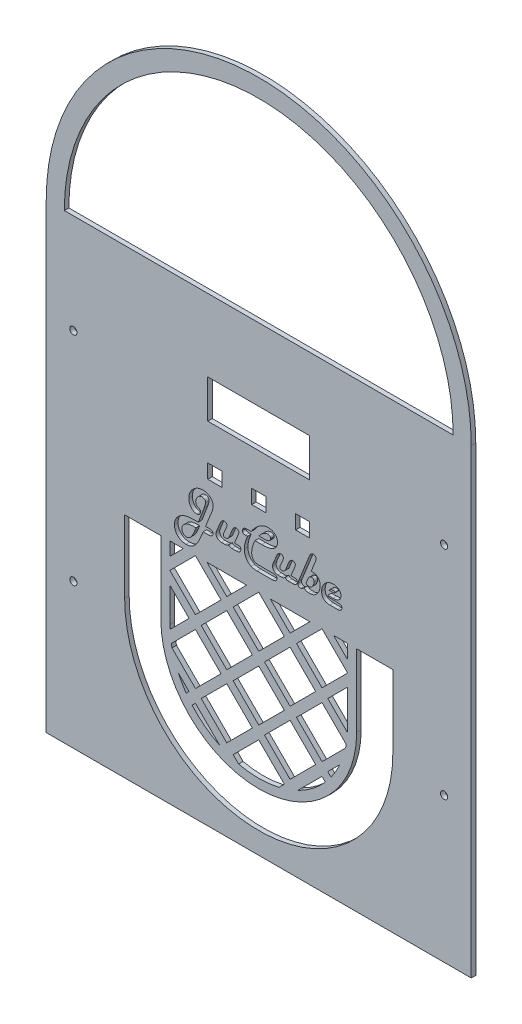
from build123d import *

# Parameters (mm, degrees)
SKETCH1_R           = 2.54
SKETCH1_W           = 71.628
SKETCH1_H           = 26.924
SKETCH1_W_2         = 9.906
SKETCH1_H_2         = 9.906
BOSS_EXTRUDE1_DEPTH = 3.175
CUT_EXTRUDE3_DEPTH  = 2.54
CUT_EXTRUDE4_DEPTH  = 4.175
CUT_EXTRUDE5_DEPTH  = 25.4


with BuildPart() as part:
    # Sketch1 → Boss-Extrude1 (new body)
    with BuildSketch(Plane.XY):
        with BuildLine():
            Line((0, 0), (0, -323.85))
            Line((0, -323.85), (298.45, -323.85))
            Line((298.45, -323.85), (298.45, 0))
            ThreePointArc((298.45, 0), (149.225, 149.225), (0, 0))
        make_face()
        with Locations((19.05, -69.85)):
            Circle(SKETCH1_R, mode=Mode.SUBTRACT)
        with Locations((19.05, -222.25)):
            Circle(SKETCH1_R, mode=Mode.SUBTRACT)
        with Locations((279.4, -69.85)):
            Circle(SKETCH1_R, mode=Mode.SUBTRACT)
        with Locations((279.4, -222.25)):
            Circle(SKETCH1_R, mode=Mode.SUBTRACT)
        with BuildLine():
            Line((12.7, 0), (285.75, 0))
            ThreePointArc((285.75, 0), (149.225, 136.525), (12.7, 0))
        make_face(mode=Mode.SUBTRACT)
        with Locations((149.225, -64.262)):
            Rectangle(SKETCH1_W, SKETCH1_H, mode=Mode.SUBTRACT)
        with Locations((118.364, -108.077)):
            Rectangle(SKETCH1_W_2, SKETCH1_H_2, mode=Mode.SUBTRACT)
        with Locations((149.225, -108.077)):
            Rectangle(SKETCH1_W_2, SKETCH1_H_2, mode=Mode.SUBTRACT)
        with Locations((180.086, -108.077)):
            Rectangle(SKETCH1_W_2, SKETCH1_H_2, mode=Mode.SUBTRACT)
    extrude(amount=BOSS_EXTRUDE1_DEPTH)

    # Sketch3 → Cut-Extrude3 (cut)
    with BuildSketch(Plane.XY.offset(3.175)):
        with BuildLine():
            Line((111.90535525, -142.473594956), (114.634550456, -142.473594956))
            add(Edge.make_bspline(
                [(114.634550456, -142.473594956), (114.832478374, -142.477826627), (115.203074422, -142.485749919), (115.717583256, -142.568194866), (116.158749376, -142.6923425), (116.518291611, -142.885660169), (116.80878151, -143.126935007), (117.009530641, -143.433806599), (117.134639848, -143.792636287), (117.14584922, -144.050935819), (117.151716551, -144.186137764)],
                knots=[0, 0, 0, 0, 0.000593217, 0.001110728, 0.001559605, 0.00196096, 0.002327158, 0.002679995, 0.003047924, 0.003452032, 0.003452032, 0.003452032, 0.003452032], degree=3))
            add(Edge.make_bspline(
                [(117.151716551, -144.186137764), (117.142623611, -144.3688148), (117.125003616, -144.722800232), (116.948227754, -145.222895393), (116.657660102, -145.657034246), (116.25720441, -146.020076712), (115.757901802, -146.301177666), (115.173849529, -146.50900938), (114.501265319, -146.624231385), (114.026079151, -146.640408721), (113.775560729, -146.648937422)],
                knots=[0, 0, 0, 0, 0.000546376, 0.001058749, 0.001568404, 0.002099416, 0.002664514, 0.00327671, 0.003950678, 0.004702195, 0.004702195, 0.004702195, 0.004702195], degree=3))
            Line((113.775560729, -146.648937422), (110.17650251, -146.648937422))
            Line((110.17650251, -146.648937422), (108.806468264, -150.025093244))
            add(Edge.make_bspline(
                [(108.806468264, -150.025093244), (108.623530561, -150.476113823), (108.269592219, -151.348724956), (107.694707707, -152.590462068), (107.119679303, -153.730823041), (106.547677927, -154.776348793), (105.953732636, -155.709392953), (105.360798138, -156.545884434), (104.767321838, -157.285246223), (104.150439583, -157.91648381), (103.517313202, -158.467290318), (102.846174483, -158.93300141), (102.142598922, -159.33567492), (101.394940149, -159.655586518), (100.613549476, -159.912784851), (99.792047744, -160.092159729), (98.934343662, -160.1950215), (98.35026586, -160.210776295), (98.052786757, -160.218800435)],
                knots=[0, 0, 0, 0, 0.001459949, 0.002824633, 0.004103528, 0.00529112, 0.006398182, 0.00741949, 0.008366231, 0.00923896, 0.010063934, 0.010879884, 0.011685718, 0.012491681, 0.013315203, 0.014150201, 0.015009982, 0.015902403, 0.015902403, 0.015902403, 0.015902403], degree=3))
            add(Edge.make_bspline(
                [(98.052786757, -160.218800435), (97.771470821, -160.213876332), (97.219304863, -160.204211319), (96.41037259, -160.08829336), (95.635534419, -159.918613957), (94.896408891, -159.671080357), (94.192319998, -159.356093583), (93.524939167, -158.96594122), (92.89207252, -158.508231786), (92.303018609, -157.982633056), (91.768244669, -157.405023998), (91.298356068, -156.788021845), (90.89565242, -156.138561716), (90.577664695, -155.447799073), (90.317844623, -154.728956071), (90.138613152, -153.972188794), (90.035923276, -153.18119214), (90.020055656, -152.64222887), (90.011990524, -152.368286737)],
                knots=[0, 0, 0, 0, 0.000843311, 0.001655248, 0.002446611, 0.003220259, 0.003989213, 0.004756627, 0.005535264, 0.00632853, 0.00712105, 0.007893072, 0.008652064, 0.009408461, 0.010170232, 0.010941641, 0.011736694, 0.012558508, 0.012558508, 0.012558508, 0.012558508], degree=3))
            add(Edge.make_bspline(
                [(90.011990524, -152.368286737), (90.015921844, -152.159684581), (90.023701515, -151.746882781), (90.09337593, -151.135173483), (90.194272266, -150.535078671), (90.34221087, -149.946398741), (90.532718901, -149.368459542), (90.767293755, -148.804324806), (91.039937957, -148.251261731), (91.356201416, -147.714830383), (91.707002647, -147.192965348), (92.101400857, -146.696580588), (92.531821115, -146.224391993), (92.993375242, -145.772688806), (93.489652047, -145.34586947), (94.025206295, -144.951332057), (94.59117916, -144.572242012), (94.990459925, -144.344977458), (95.193112099, -144.229630915)],
                knots=[0, 0, 0, 0, 0.000625592, 0.001237981, 0.001844868, 0.002450096, 0.003056982, 0.003668816, 0.004281519, 0.004905313, 0.005535612, 0.006166473, 0.006805366, 0.007451252, 0.008102856, 0.008767217, 0.009445753, 0.010145075, 0.010145075, 0.010145075, 0.010145075], degree=3))
            add(Edge.make_bspline(
                [(95.193112099, -144.229630915), (95.466306799, -144.090514363), (96.025496846, -143.805762898), (96.931112347, -143.464014052), (97.904599722, -143.161091862), (98.956974743, -142.929090313), (100.079229838, -142.734422113), (101.278180694, -142.611062871), (102.551269272, -142.525489747), (103.425846106, -142.516349904), (103.875432305, -142.511651463)],
                knots=[0, 0, 0, 0, 0.000919098, 0.001881261, 0.002899323, 0.003975518, 0.005111516, 0.006314674, 0.007589459, 0.008938021, 0.008938021, 0.008938021, 0.008938021], degree=3))
            Line((103.875432305, -142.511651463), (106.800346688, -142.473594956))
            Line((106.800346688, -142.473594956), (110.883266209, -131.736223381))
            add(Edge.make_bspline(
                [(110.883266209, -131.736223381), (110.965722331, -131.511828047), (111.122901044, -131.084083342), (111.333736407, -130.466845729), (111.522579557, -129.909156956), (111.668610734, -129.402438211), (111.783837147, -128.952902971), (111.866718302, -128.559581734), (111.920521095, -128.221999442), (111.928786328, -128.014085457), (111.932538469, -127.919699408)],
                knots=[0, 0, 0, 0, 0.000717163, 0.001367064, 0.001956758, 0.002483243, 0.002948704, 0.003348546, 0.003689151, 0.003972327, 0.003972327, 0.003972327, 0.003972327], degree=3))
            add(Edge.make_bspline(
                [(111.932538469, -127.919699408), (111.925417179, -127.778778004), (111.911254061, -127.498507672), (111.757328477, -127.099093563), (111.52628619, -126.726622452), (111.201710473, -126.401120025), (110.82452526, -126.120549929), (110.39683875, -125.915316763), (109.933335048, -125.79172576), (109.611853781, -125.778808912), (109.447992236, -125.772225093)],
                knots=[0, 0, 0, 0, 0.000420875, 0.000837053, 0.001266961, 0.00172834, 0.002206795, 0.002671239, 0.00314332, 0.003634095, 0.003634095, 0.003634095, 0.003634095], degree=3))
            add(Edge.make_bspline(
                [(109.447992236, -125.772225093), (109.308092934, -125.777722214), (109.029865685, -125.788654713), (108.617548066, -125.868750723), (108.214232483, -125.993563773), (107.819157296, -126.168902888), (107.436010971, -126.399357172), (107.06850339, -126.68696572), (106.700087147, -127.012600697), (106.353183845, -127.389841903), (106.033841309, -127.796596885), (105.744301745, -128.215667633), (105.514978744, -128.65359035), (105.313585179, -129.096036159), (105.162384605, -129.553803305), (105.054097307, -130.021487099), (104.985568031, -130.500084182), (104.977645872, -130.822636849), (104.97363436, -130.985966531)],
                knots=[0, 0, 0, 0, 0.000419503, 0.000834295, 0.001255591, 0.001683948, 0.00212776, 0.002593157, 0.003082122, 0.003601457, 0.004127886, 0.004633026, 0.005126804, 0.005608706, 0.006090087, 0.006570116, 0.007047582, 0.007537363, 0.007537363, 0.007537363, 0.007537363], degree=3))
            add(Edge.make_bspline(
                [(104.97363436, -130.985966531), (104.979856751, -131.154911956), (104.991801412, -131.479223894), (105.082852255, -131.938769706), (105.237585257, -132.344623468), (105.452096985, -132.708114169), (105.763718356, -133.017675774), (106.150125877, -133.306995127), (106.625419515, -133.577978575), (106.981558843, -133.728123486), (107.170038469, -133.807584682)],
                knots=[0, 0, 0, 0, 0.000506659, 0.000972596, 0.001397663, 0.001805121, 0.002228063, 0.002705405, 0.003250942, 0.003864223, 0.003864223, 0.003864223, 0.003864223], degree=3))
            add(Edge.make_bspline(
                [(107.170038469, -133.807584682), (107.270955932, -133.852270837), (107.46577068, -133.93853462), (107.728699287, -134.103433549), (107.953338883, -134.286852987), (108.134796569, -134.491638266), (108.283203492, -134.712139497), (108.377482635, -134.959866908), (108.440301409, -135.223447985), (108.448770973, -135.405580249), (108.453086414, -135.498380915)],
                knots=[0, 0, 0, 0, 0.000330743, 0.000638478, 0.000928053, 0.001197592, 0.00145696, 0.001720455, 0.001988179, 0.002266299, 0.002266299, 0.002266299, 0.002266299], degree=3))
            add(Edge.make_bspline(
                [(108.453086414, -135.498380915), (108.443922003, -135.6661088), (108.425915779, -135.995660348), (108.275870608, -136.469086226), (108.014028156, -136.889397892), (107.67471744, -137.265030041), (107.254542296, -137.564701486), (106.784637277, -137.796076577), (106.259958499, -137.926462446), (105.894926154, -137.942220043), (105.707581277, -137.950307285)],
                knots=[0, 0, 0, 0, 0.000502559, 0.000987427, 0.001470402, 0.001978372, 0.002495996, 0.003009061, 0.003541769, 0.00410343, 0.00410343, 0.00410343, 0.00410343], degree=3))
            add(Edge.make_bspline(
                [(105.707581277, -137.950307285), (105.516995055, -137.943264009), (105.141099258, -137.929372461), (104.587517044, -137.842268554), (104.055478107, -137.690004827), (103.548348223, -137.466761032), (103.056452612, -137.197712302), (102.58987538, -136.859144735), (102.144385528, -136.463111121), (101.729971353, -136.005973177), (101.347955563, -135.512901136), (101.010461447, -134.987242145), (100.737650286, -134.429432461), (100.500112594, -133.853899826), (100.318846966, -133.249484268), (100.197483123, -132.619026977), (100.118285912, -131.962931929), (100.10775746, -131.517179387), (100.102401483, -131.290418586)],
                knots=[0, 0, 0, 0, 0.000571779, 0.001127727, 0.001676613, 0.002227004, 0.002786741, 0.00335554, 0.003952408, 0.004571923, 0.005203721, 0.00582209, 0.006442082, 0.007063978, 0.00768834, 0.008331268, 0.00898809, 0.009668214, 0.009668214, 0.009668214, 0.009668214], degree=3))
            add(Edge.make_bspline(
                [(100.102401483, -131.290418586), (100.111891643, -130.958249715), (100.130648113, -130.30174707), (100.277369528, -129.33487824), (100.508242542, -128.39866099), (100.846240866, -127.500063312), (101.2612477, -126.627009535), (101.793811409, -125.801013426), (102.402569477, -124.99607617), (103.103536387, -124.238608487), (103.869607513, -123.547238087), (104.666327023, -122.922353373), (105.511513176, -122.415310034), (106.378349286, -121.981352104), (107.287532091, -121.659456361), (108.222994042, -121.414761101), (109.195770925, -121.279330634), (109.853540812, -121.25916964), (110.187375798, -121.248937422)],
                knots=[0, 0, 0, 0, 0.000996108, 0.001968721, 0.002927329, 0.003883715, 0.004844172, 0.005821559, 0.006826279, 0.007868939, 0.008911939, 0.009919964, 0.010900852, 0.011863691, 0.012823317, 0.013788531, 0.014760368, 0.015761907, 0.015761907, 0.015761907, 0.015761907], degree=3))
            add(Edge.make_bspline(
                [(110.187375798, -121.248937422), (110.430478744, -121.253565467), (110.909242899, -121.262679887), (111.609592432, -121.352044036), (112.280175801, -121.495125478), (112.921525491, -121.686451853), (113.52932949, -121.947063304), (114.107176811, -122.256464192), (114.655084887, -122.622359305), (115.162379431, -123.046080963), (115.627010587, -123.509570507), (116.037805274, -124.004678382), (116.383031928, -124.529527165), (116.662848907, -125.084456209), (116.87991109, -125.668293487), (117.038994409, -126.279934149), (117.132494757, -126.921914625), (117.145222848, -127.359418698), (117.151716551, -127.58262749)],
                knots=[0, 0, 0, 0, 0.000729017, 0.001435718, 0.002113884, 0.002784599, 0.003439934, 0.004094254, 0.004748665, 0.005412737, 0.006073954, 0.006715063, 0.007339331, 0.007954465, 0.008575505, 0.00920449, 0.009847257, 0.010516759, 0.010516759, 0.010516759, 0.010516759], degree=3))
            add(Edge.make_bspline(
                [(117.151716551, -127.58262749), (117.138983203, -127.886021046), (117.112177017, -128.52472373), (116.917724713, -129.522284277), (116.611257329, -130.604307412), (116.334626311, -131.343044659), (116.189430593, -131.730786737)],
                knots=[0, 0, 0, 0, 0.000909887, 0.00191549, 0.003039403, 0.004280983, 0.004280983, 0.004280983, 0.004280983], degree=3))
            Line((116.189430593, -131.730786737), (111.90535525, -142.473594956))
        make_face()
        with BuildLine():
            add(Edge.make_bspline(
                [(105.169353538, -146.648937422), (104.859404522, -146.650164761), (104.259187169, -146.652541509), (103.387486439, -146.695206769), (102.571113383, -146.744975331), (101.809009222, -146.825383809), (101.10433082, -146.936121594), (100.453437913, -147.057522213), (99.859442252, -147.208256485), (99.487383632, -147.333562323), (99.308651483, -147.393757627)],
                knots=[0, 0, 0, 0, 0.00092973, 0.001800425, 0.002617732, 0.003383218, 0.004098297, 0.004757231, 0.005369064, 0.005934711, 0.005934711, 0.005934711, 0.005934711], degree=3))
            add(Edge.make_bspline(
                [(99.308651483, -147.393757627), (99.00584563, -147.512540454), (98.41762445, -147.743284258), (97.619830629, -148.214558443), (96.913999856, -148.748218998), (96.31581194, -149.355592132), (95.833892884, -150.017758313), (95.481964323, -150.723479112), (95.274489467, -151.468666713), (95.245630277, -151.97742569), (95.231168606, -152.232370641)],
                knots=[0, 0, 0, 0, 0.000974434, 0.001892905, 0.002769335, 0.003622802, 0.004440615, 0.005216228, 0.005977241, 0.006741646, 0.006741646, 0.006741646, 0.006741646], degree=3))
            add(Edge.make_bspline(
                [(95.231168606, -152.232370641), (95.24233771, -152.46550329), (95.264136051, -152.920499961), (95.444611458, -153.574036631), (95.737232717, -154.171926989), (96.138123977, -154.70121799), (96.623274053, -155.142392153), (97.174736484, -155.464398769), (97.781060047, -155.65825016), (98.201791499, -155.682901099), (98.417041894, -155.695512764)],
                knots=[0, 0, 0, 0, 0.000698455, 0.00136315, 0.002017199, 0.002684823, 0.003343106, 0.003971597, 0.004587163, 0.005231996, 0.005231996, 0.005231996, 0.005231996], degree=3))
            add(Edge.make_bspline(
                [(98.417041894, -155.695512764), (98.556890023, -155.691802591), (98.834798823, -155.684429665), (99.245536895, -155.610603889), (99.645440177, -155.491003412), (100.0322397, -155.319500239), (100.41065156, -155.106806543), (100.776235736, -154.843346775), (101.128606313, -154.531374449), (101.475057634, -154.174240023), (101.813076679, -153.76206201), (102.148262329, -153.293786693), (102.484546052, -152.770591915), (102.823353275, -152.193704922), (103.153216136, -151.554949052), (103.482796372, -150.859559527), (103.817339865, -150.109058011), (104.024258376, -149.583759613), (104.130954565, -149.312892901)],
                knots=[0, 0, 0, 0, 0.000419186, 0.000833014, 0.00124752, 0.001668711, 0.002099615, 0.002547701, 0.003017711, 0.00350984, 0.004038873, 0.00461526, 0.005236562, 0.005904185, 0.006621534, 0.007392407, 0.008212692, 0.009085963, 0.009085963, 0.009085963, 0.009085963], degree=3))
            Line((104.130954565, -149.312892901), (105.169353538, -146.648937422))
        make_face(mode=Mode.SUBTRACT)
        with BuildLine():
            Line((132.162290182, -142.473594956), (134.288017921, -142.473594956))
            add(Edge.make_bspline(
                [(134.288017921, -142.473594956), (134.485900768, -142.475874366), (134.852613126, -142.480098521), (135.354381047, -142.55669005), (135.769522285, -142.669970764), (136.099074898, -142.845072202), (136.345820374, -143.085969294), (136.519487229, -143.387950707), (136.62218335, -143.753769835), (136.631641683, -144.018716211), (136.636648058, -144.158954545)],
                knots=[0, 0, 0, 0, 0.000592993, 0.001098922, 0.001518637, 0.001878771, 0.002205558, 0.00253937, 0.002912761, 0.003332651, 0.003332651, 0.003332651, 0.003332651], degree=3))
            add(Edge.make_bspline(
                [(136.636648058, -144.158954545), (136.629257965, -144.345148997), (136.615043562, -144.703282912), (136.449481666, -145.205120361), (136.187578335, -145.643565606), (135.821747063, -146.011927513), (135.361692351, -146.300905167), (134.817423584, -146.509142975), (134.191274087, -146.623811238), (133.748438545, -146.640289), (133.516014497, -146.648937422)],
                knots=[0, 0, 0, 0, 0.000556692, 0.001070764, 0.001565857, 0.002077162, 0.002612554, 0.003183997, 0.003815209, 0.004512458, 0.004512458, 0.004512458, 0.004512458], degree=3))
            Line((133.516014497, -146.648937422), (130.23228162, -146.648937422))
            add(Edge.make_bspline(
                [(130.23228162, -146.648937422), (130.108879959, -146.6440815), (129.871707587, -146.63474864), (129.530721253, -146.582790189), (129.221564993, -146.485337048), (128.948353029, -146.341549623), (128.704324562, -146.164510497), (128.487865828, -145.952010349), (128.313846091, -145.690139012), (128.223669948, -145.497642748), (128.17723025, -145.39850934)],
                knots=[0, 0, 0, 0, 0.000370331, 0.000711759, 0.001031552, 0.00133794, 0.001633725, 0.001933579, 0.002242704, 0.002570935, 0.002570935, 0.002570935, 0.002570935], degree=3))
            add(Edge.make_bspline(
                [(128.17723025, -145.39850934), (128.091891573, -145.497855941), (127.925498795, -145.691561276), (127.652750936, -145.951880909), (127.356397918, -146.164426959), (127.044540425, -146.336909183), (126.721646257, -146.484204894), (126.378717265, -146.580063002), (126.018814033, -146.634563073), (125.77442256, -146.644067261), (125.649190866, -146.648937422)],
                knots=[0, 0, 0, 0, 0.000392795, 0.000765869, 0.001128009, 0.001483392, 0.001833919, 0.002190133, 0.002547672, 0.002923431, 0.002923431, 0.002923431, 0.002923431], degree=3))
            Line((125.649190866, -146.648937422), (122.968925456, -146.648937422))
            add(Edge.make_bspline(
                [(122.968925456, -146.648937422), (122.710342074, -146.638892963), (122.209551797, -146.619440178), (121.495513249, -146.42765411), (120.849744348, -146.118845457), (120.285667377, -145.689535381), (119.823287493, -145.16396696), (119.481743816, -144.561906183), (119.27297581, -143.89157646), (119.250755719, -143.421071742), (119.239387784, -143.180358655)],
                knots=[0, 0, 0, 0, 0.000774316, 0.001499594, 0.002199888, 0.002909927, 0.003611106, 0.004285447, 0.004973349, 0.005693946, 0.005693946, 0.005693946, 0.005693946], degree=3))
            add(Edge.make_bspline(
                [(119.239387784, -143.180358655), (119.244295913, -143.031293371), (119.254617414, -142.717818032), (119.357434279, -142.234807009), (119.502325849, -141.713810893), (119.640127581, -141.363394111), (119.712375798, -141.179673723)],
                knots=[0, 0, 0, 0, 0.000446633, 0.000939242, 0.001476178, 0.002067948, 0.002067948, 0.002067948, 0.002067948], degree=3))
            Line((119.712375798, -141.179673723), (122.186048743, -135.215675435))
            add(Edge.make_bspline(
                [(122.186048743, -135.215675435), (122.273135849, -135.020031022), (122.439519661, -134.646243621), (122.732782882, -134.138663174), (123.050269894, -133.704475528), (123.396859964, -133.351997067), (123.765313241, -133.068762421), (124.164875155, -132.879985401), (124.584592738, -132.749940394), (124.876193537, -132.737456195), (125.023976825, -132.731129203)],
                knots=[0, 0, 0, 0, 0.0006421, 0.00122676, 0.001755206, 0.002251134, 0.002705639, 0.003140876, 0.003571024, 0.004013034, 0.004013034, 0.004013034, 0.004013034], degree=3))
            add(Edge.make_bspline(
                [(125.023976825, -132.731129203), (125.14976699, -132.734845329), (125.394205904, -132.742066607), (125.742476559, -132.842089431), (126.066444774, -132.987776515), (126.348062463, -133.200425949), (126.589559856, -133.447306592), (126.768554206, -133.729396898), (126.877817585, -134.042686121), (126.888662592, -134.261584411), (126.894182305, -134.372995641)],
                knots=[0, 0, 0, 0, 0.000376112, 0.000730871, 0.001078689, 0.001436435, 0.001782506, 0.002109836, 0.002431334, 0.00276457, 0.00276457, 0.00276457, 0.00276457], degree=3))
            add(Edge.make_bspline(
                [(126.894182305, -134.372995641), (126.891089128, -134.462038924), (126.884597601, -134.648910505), (126.825516857, -134.93856838), (126.733025714, -135.247292452), (126.649444088, -135.45549904), (126.606040182, -135.563620641)],
                knots=[0, 0, 0, 0, 0.000266894, 0.000560121, 0.000883498, 0.001232842, 0.001232842, 0.001232842, 0.001232842], degree=3))
            Line((126.606040182, -135.563620641), (126.410321003, -136.025735367))
            Line((126.410321003, -136.025735367), (124.529242236, -140.462036737))
            Line((124.529242236, -140.462036737), (124.491185729, -140.989391189))
            add(Edge.make_bspline(
                [(124.491185729, -140.989391189), (124.483300228, -141.123465853), (124.469771223, -141.353495233), (124.461864208, -141.583782617), (124.458565866, -141.679844956)],
                knots=[0, 0, 0, 0, 0.000402899, 0.000691246, 0.000691246, 0.000691246, 0.000691246], degree=3))
            add(Edge.make_bspline(
                [(124.458565866, -141.679844956), (124.457284795, -141.741771327), (124.454834372, -141.860223595), (124.500210212, -142.025922886), (124.576808765, -142.169748704), (124.698087302, -142.279856459), (124.848319618, -142.36731541), (125.030414977, -142.432445492), (125.247173975, -142.469872072), (125.402570334, -142.472293504), (125.486091551, -142.473594956)],
                knots=[0, 0, 0, 0, 0.000184926, 0.000353725, 0.000509501, 0.000667164, 0.000837791, 0.001028694, 0.001244112, 0.001494434, 0.001494434, 0.001494434, 0.001494434], degree=3))
            add(Edge.make_bspline(
                [(125.486091551, -142.473594956), (125.662173594, -142.468627258), (126.001876747, -142.459043414), (126.489268216, -142.378933499), (126.929020173, -142.237335344), (127.321854667, -142.039310087), (127.669063594, -141.7859375), (127.971196492, -141.478312434), (128.226909847, -141.11248342), (128.351907801, -140.83768644), (128.416442579, -140.695812422)],
                knots=[0, 0, 0, 0, 0.000528055, 0.00101874, 0.001476065, 0.00190885, 0.002332943, 0.002759677, 0.003197048, 0.003663872, 0.003663872, 0.003663872, 0.003663872], degree=3))
            Line((128.416442579, -140.695812422), (130.634593264, -135.221112079))
            add(Edge.make_bspline(
                [(130.634593264, -135.221112079), (130.718261161, -135.025679297), (130.877946885, -134.652682887), (131.159695344, -134.140338403), (131.476192223, -133.709075096), (131.812665216, -133.350673449), (132.176847352, -133.067606671), (132.57543298, -132.880123875), (132.995062824, -132.749904834), (133.28667552, -132.737444235), (133.434464839, -132.731129203)],
                knots=[0, 0, 0, 0, 0.000637573, 0.001216849, 0.001749668, 0.002238029, 0.002688188, 0.003123426, 0.003553574, 0.003995583, 0.003995583, 0.003995583, 0.003995583], degree=3))
            add(Edge.make_bspline(
                [(133.434464839, -132.731129203), (133.554699134, -132.737460842), (133.789820031, -132.749842507), (134.1302058, -132.84614852), (134.442532539, -133.00475), (134.718211977, -133.223867317), (134.950094014, -133.48006178), (135.125706621, -133.767968657), (135.227064448, -134.08731416), (135.238852015, -134.308866686), (135.244867236, -134.421925435)],
                knots=[0, 0, 0, 0, 0.000360298, 0.000704571, 0.001052262, 0.001404638, 0.001754996, 0.002084126, 0.002409099, 0.002747746, 0.002747746, 0.002747746, 0.002747746], degree=3))
            add(Edge.make_bspline(
                [(135.244867236, -134.421925435), (135.238630948, -134.527421695), (135.224493517, -134.76657773), (135.127820239, -135.157333764), (134.978569486, -135.623057617), (134.84833765, -135.953993006), (134.777315866, -136.134468244)],
                knots=[0, 0, 0, 0, 0.000316495, 0.000717482, 0.00120235, 0.001783944, 0.001783944, 0.001783944, 0.001783944], degree=3))
            Line((134.777315866, -136.134468244), (132.162290182, -142.473594956))
        make_face()
        with BuildLine():
            add(Edge.make_bspline(
                [(146.640072716, -133.774964819), (146.453590686, -134.148450677), (146.087972213, -134.880710669), (145.608918113, -135.985096191), (145.204973615, -137.070558714), (144.871831909, -138.133417111), (144.614820206, -139.177636764), (144.42769274, -140.201168867), (144.315984093, -141.206180751), (144.299534116, -141.869867137), (144.291442579, -142.19632612)],
                knots=[0, 0, 0, 0, 0.0012522, 0.002455075, 0.003609347, 0.004725343, 0.005794719, 0.006833388, 0.007845028, 0.008824363, 0.008824363, 0.008824363, 0.008824363], degree=3))
            add(Edge.make_bspline(
                [(144.291442579, -142.19632612), (144.293342874, -142.417584376), (144.297026563, -142.846489626), (144.359975448, -143.463715225), (144.450193466, -144.034701415), (144.57722769, -144.556556662), (144.749834446, -145.027829239), (144.944596152, -145.457106377), (145.196255556, -145.828060387), (145.472091065, -146.161992844), (145.803876721, -146.443585691), (146.177625491, -146.688044334), (146.605213277, -146.889608886), (147.076963707, -147.05648381), (147.599293162, -147.187917947), (148.170917921, -147.275467406), (148.791546028, -147.339599109), (149.222294347, -147.343043807), (149.445380935, -147.344827833)],
                knots=[0, 0, 0, 0, 0.000663471, 0.001286127, 0.001859042, 0.002397023, 0.002894022, 0.003363372, 0.003806683, 0.0042348, 0.004658788, 0.005106644, 0.005571087, 0.006073204, 0.006605912, 0.007184193, 0.007806849, 0.008475755, 0.008475755, 0.008475755, 0.008475755], degree=3))
            Line((149.445380935, -147.344827833), (159.649961414, -147.344827833))
            add(Edge.make_bspline(
                [(159.649961414, -147.344827833), (159.836956821, -147.34959977), (160.187325265, -147.358540825), (160.676668967, -147.434893655), (161.095123109, -147.552845118), (161.439726052, -147.735388192), (161.70786265, -147.97457459), (161.906346536, -148.263890565), (162.016499227, -148.611361816), (162.029699689, -148.85726003), (162.036648058, -148.986694271)],
                knots=[0, 0, 0, 0, 0.000560634, 0.001050445, 0.001482136, 0.00185919, 0.002209548, 0.002550326, 0.002899332, 0.003287205, 0.003287205, 0.003287205, 0.003287205], degree=3))
            add(Edge.make_bspline(
                [(162.036648058, -148.986694271), (162.02700031, -149.176429403), (162.008533159, -149.539609231), (161.844558536, -150.052730499), (161.572008704, -150.499992993), (161.187954304, -150.871620383), (160.711235566, -151.170920157), (160.141100209, -151.37140833), (159.490604509, -151.498075111), (159.029034053, -151.512539623), (158.785535045, -151.520170298)],
                knots=[0, 0, 0, 0, 0.000568019, 0.001087268, 0.001597299, 0.002123981, 0.002676061, 0.003272929, 0.003926526, 0.004656334, 0.004656334, 0.004656334, 0.004656334], degree=3))
            Line((158.785535045, -151.520170298), (148.146023058, -151.520170298))
            add(Edge.make_bspline(
                [(148.146023058, -151.520170298), (147.928475163, -151.518877628), (147.503896272, -151.516354778), (146.884087327, -151.473680962), (146.295801345, -151.423526475), (145.741658867, -151.343669966), (145.222607625, -151.230367811), (144.733725303, -151.110993758), (144.279885332, -150.957953572), (143.995299505, -150.835210253), (143.856511072, -150.775350093)],
                knots=[0, 0, 0, 0, 0.000652488, 0.001273433, 0.001863102, 0.002423604, 0.002951406, 0.003456429, 0.003932656, 0.004385988, 0.004385988, 0.004385988, 0.004385988], degree=3))
            add(Edge.make_bspline(
                [(143.856511072, -150.775350093), (143.673805659, -150.685696635), (143.312174746, -150.508244521), (142.798168356, -150.194631836), (142.312302814, -149.846363794), (141.85857678, -149.460151052), (141.429373288, -149.046080087), (141.037333412, -148.591087306), (140.674072123, -148.101095412), (140.337176384, -147.581495837), (140.03706637, -147.033433897), (139.785925135, -146.459435535), (139.555636033, -145.873428282), (139.388689271, -145.260966789), (139.242270306, -144.636518493), (139.147387761, -143.990888283), (139.085333424, -143.326552815), (139.076662303, -142.87605194), (139.072264497, -142.647567559)],
                knots=[0, 0, 0, 0, 0.000610286, 0.001207946, 0.001803922, 0.002401879, 0.002993949, 0.003591312, 0.004201308, 0.004822609, 0.005447847, 0.006073274, 0.006701318, 0.007334588, 0.007975582, 0.008624526, 0.009290488, 0.00997585, 0.00997585, 0.00997585, 0.00997585], degree=3))
            add(Edge.make_bspline(
                [(139.072264497, -142.647567559), (139.080843341, -142.330193648), (139.098434221, -141.679419923), (139.205467421, -140.680216796), (139.385324056, -139.636111292), (139.646458423, -138.549374896), (139.96479012, -137.415465457), (140.3675414, -136.240606891), (140.832474917, -135.017120839), (141.189178305, -134.195824199), (141.371964839, -133.774964819)],
                knots=[0, 0, 0, 0, 0.000952173, 0.001952427, 0.003011569, 0.004128518, 0.005303952, 0.006543519, 0.007853073, 0.009229414, 0.009229414, 0.009229414, 0.009229414], degree=3))
            Line((141.371964839, -133.774964819), (140.344439154, -133.774964819))
            Line((140.344439154, -133.774964819), (139.866014497, -133.774964819))
            add(Edge.make_bspline(
                [(139.866014497, -133.774964819), (139.695369684, -133.769864414), (139.373923681, -133.760256711), (138.924502174, -133.687158349), (138.540719731, -133.559671446), (138.227516456, -133.371145755), (137.97826012, -133.131366155), (137.800203755, -132.833875682), (137.695566993, -132.482423988), (137.685665575, -132.231696538), (137.680483675, -132.100478518)],
                knots=[0, 0, 0, 0, 0.000511767, 0.000964023, 0.001361195, 0.001717368, 0.002051843, 0.002388433, 0.002746179, 0.003138974, 0.003138974, 0.003138974, 0.003138974], degree=3))
            add(Edge.make_bspline(
                [(137.680483675, -132.100478518), (137.689677771, -131.930250599), (137.707765224, -131.595362929), (137.890813427, -131.121396113), (138.166589686, -130.685178696), (138.558921128, -130.311664553), (139.018952699, -129.991564427), (139.543611334, -129.76260192), (140.114092368, -129.621081594), (140.510309291, -129.606911648), (140.714130935, -129.599622353)],
                knots=[0, 0, 0, 0, 0.000508522, 0.001000411, 0.001504115, 0.002046174, 0.002613177, 0.003177882, 0.003754114, 0.00436457, 0.00436457, 0.00436457, 0.00436457], degree=3))
            Line((140.714130935, -129.599622353), (141.208865524, -129.599622353))
            Line((141.208865524, -129.599622353), (143.86738436, -129.599622353))
            add(Edge.make_bspline(
                [(143.86738436, -129.599622353), (144.160693116, -129.148426284), (144.759929233, -128.226622983), (145.821578043, -126.918605418), (147.005272376, -125.619448303), (147.885773053, -124.810615759), (148.336305593, -124.396754203)],
                knots=[0, 0, 0, 0, 0.001613429, 0.00329627, 0.005046945, 0.006881351, 0.006881351, 0.006881351, 0.006881351], degree=3))
            add(Edge.make_bspline(
                [(148.336305593, -124.396754203), (148.63273669, -124.144604701), (149.214235634, -123.649971477), (150.146604092, -123.017388235), (151.085295289, -122.466523443), (152.050431962, -122.025828489), (153.029163408, -121.672807866), (154.029985603, -121.430100775), (155.04579554, -121.276720593), (155.729600716, -121.258219159), (156.072649771, -121.248937422)],
                knots=[0, 0, 0, 0, 0.001166689, 0.002288655, 0.003375018, 0.004428339, 0.005466951, 0.006491496, 0.00751331, 0.008542, 0.008542, 0.008542, 0.008542], degree=3))
            add(Edge.make_bspline(
                [(156.072649771, -121.248937422), (156.295778189, -121.254301489), (156.732488381, -121.264800118), (157.372611015, -121.342929168), (157.983717229, -121.467622036), (158.567705473, -121.63965272), (159.121422704, -121.870014257), (159.641804614, -122.154206037), (160.13750217, -122.482063939), (160.595116016, -122.860773817), (161.012456453, -123.277180361), (161.381396881, -123.72533672), (161.689446806, -124.205109794), (161.950532324, -124.708946274), (162.146447685, -125.244509564), (162.278492265, -125.809036901), (162.371685407, -126.398000456), (162.380240206, -126.801185162), (162.384593264, -127.006343244)],
                knots=[0, 0, 0, 0, 0.000669259, 0.001309884, 0.001931495, 0.002538674, 0.003133359, 0.003726925, 0.004314988, 0.004913636, 0.005505656, 0.006081351, 0.006651369, 0.00721303, 0.007780632, 0.008356865, 0.008950431, 0.009565373, 0.009565373, 0.009565373, 0.009565373], degree=3))
            add(Edge.make_bspline(
                [(162.384593264, -127.006343244), (162.374680809, -127.297087542), (162.355309847, -127.8652613), (162.188058413, -128.689703015), (161.912959299, -129.459283999), (161.534578741, -130.181516833), (161.041310707, -130.848860154), (160.432293873, -131.453361215), (159.725857577, -132.017104096), (159.192242013, -132.329964074), (158.916014497, -132.491916874)],
                knots=[0, 0, 0, 0, 0.00087156, 0.001703207, 0.002511422, 0.003316376, 0.004140597, 0.004990193, 0.005884269, 0.006843787, 0.006843787, 0.006843787, 0.006843787], degree=3))
            add(Edge.make_bspline(
                [(158.916014497, -132.491916874), (158.707637996, -132.595808964), (158.271280581, -132.813367489), (157.545956629, -133.068552673), (156.737698369, -133.290687686), (155.841273034, -133.466421374), (154.861650854, -133.608329887), (153.794352805, -133.701803847), (152.641021191, -133.762590129), (151.843025573, -133.770742719), (151.429755935, -133.774964819)],
                knots=[0, 0, 0, 0, 0.000697947, 0.001461559, 0.002301727, 0.003211208, 0.00419996, 0.005270026, 0.006424145, 0.007663891, 0.007663891, 0.007663891, 0.007663891], degree=3))
            Line((151.429755935, -133.774964819), (146.640072716, -133.774964819))
        make_face()
        with BuildLine():
            Line((149.374704565, -129.599622353), (152.930269634, -129.599622353))
            add(Edge.make_bspline(
                [(152.930269634, -129.599622353), (153.115130685, -129.597050372), (153.474180953, -129.592054887), (153.993272119, -129.567601187), (154.477116863, -129.515842767), (154.926302122, -129.454868952), (155.339537985, -129.366101406), (155.717220663, -129.266135612), (156.055956448, -129.138727665), (156.363291072, -128.998808743), (156.634735162, -128.838337678), (156.868072142, -128.653212006), (157.070234463, -128.456426529), (157.231026311, -128.232525952), (157.355756822, -127.992160255), (157.450658384, -127.733451013), (157.505490956, -127.454466683), (157.510702646, -127.262103174), (157.513360387, -127.164005915)],
                knots=[0, 0, 0, 0, 0.000554644, 0.001077269, 0.00155819, 0.002014123, 0.002436365, 0.002825456, 0.003184974, 0.00352064, 0.003837648, 0.004128038, 0.004412515, 0.00468112, 0.004951043, 0.005222766, 0.005505315, 0.005799347, 0.005799347, 0.005799347, 0.005799347], degree=3))
            add(Edge.make_bspline(
                [(157.513360387, -127.164005915), (157.505855232, -127.041866517), (157.491198057, -126.803334662), (157.381105056, -126.460413491), (157.181133323, -126.16210901), (156.919813225, -125.899672194), (156.596915968, -125.692062416), (156.235936157, -125.528268378), (155.828082564, -125.444370956), (155.545615827, -125.431160138), (155.398505935, -125.424279888)],
                knots=[0, 0, 0, 0, 0.000366238, 0.000715243, 0.001065095, 0.001434146, 0.001818652, 0.002210581, 0.002616877, 0.003058451, 0.003058451, 0.003058451, 0.003058451], degree=3))
            add(Edge.make_bspline(
                [(155.398505935, -125.424279888), (155.15606138, -125.43873236), (154.655190323, -125.468590012), (153.897137171, -125.698595524), (153.119075944, -126.064539024), (152.321599514, -126.558975883), (151.529801499, -127.169651967), (150.766968235, -127.886543443), (150.041309381, -128.699702796), (149.600245884, -129.295140538), (149.374704565, -129.599622353)],
                knots=[0, 0, 0, 0, 0.00072652, 0.001500931, 0.002357181, 0.003301734, 0.004309759, 0.005352135, 0.006437968, 0.007574279, 0.007574279, 0.007574279, 0.007574279], degree=3))
        make_face(mode=Mode.SUBTRACT)
        with BuildLine():
            Line((171.828043606, -142.473594956), (173.953771346, -142.473594956))
            add(Edge.make_bspline(
                [(173.953771346, -142.473594956), (174.151654192, -142.475874366), (174.51836655, -142.480098521), (175.020134472, -142.55669005), (175.43527571, -142.669970764), (175.764828323, -142.845072202), (176.011573799, -143.085969294), (176.185240653, -143.387950707), (176.287936775, -143.753769835), (176.297395108, -144.018716211), (176.302401483, -144.158954545)],
                knots=[0, 0, 0, 0, 0.000592993, 0.001098922, 0.001518637, 0.001878771, 0.002205558, 0.00253937, 0.002912761, 0.003332651, 0.003332651, 0.003332651, 0.003332651], degree=3))
            add(Edge.make_bspline(
                [(176.302401483, -144.158954545), (176.29501139, -144.345148997), (176.280796987, -144.703282912), (176.11523509, -145.205120361), (175.853331759, -145.643565606), (175.487500488, -146.011927513), (175.027445776, -146.300905167), (174.483177009, -146.509142975), (173.857027512, -146.623811238), (173.41419197, -146.640289), (173.181767921, -146.648937422)],
                knots=[0, 0, 0, 0, 0.000556692, 0.001070764, 0.001565857, 0.002077162, 0.002612554, 0.003183997, 0.003815209, 0.004512458, 0.004512458, 0.004512458, 0.004512458], degree=3))
            Line((173.181767921, -146.648937422), (169.898035045, -146.648937422))
            add(Edge.make_bspline(
                [(169.898035045, -146.648937422), (169.774633383, -146.6440815), (169.537461012, -146.63474864), (169.196474677, -146.582790189), (168.887318418, -146.485337048), (168.614106453, -146.341549623), (168.370077987, -146.164510497), (168.153619252, -145.952010349), (167.979599516, -145.690139012), (167.889423373, -145.497642748), (167.842983675, -145.39850934)],
                knots=[0, 0, 0, 0, 0.000370331, 0.000711759, 0.001031552, 0.00133794, 0.001633725, 0.001933579, 0.002242704, 0.002570935, 0.002570935, 0.002570935, 0.002570935], degree=3))
            add(Edge.make_bspline(
                [(167.842983675, -145.39850934), (167.757644998, -145.497855941), (167.59125222, -145.691561276), (167.318504361, -145.951880909), (167.022151343, -146.164426959), (166.71029385, -146.336909183), (166.387399682, -146.484204894), (166.04447069, -146.580063002), (165.684567457, -146.634563073), (165.440175985, -146.644067261), (165.314944291, -146.648937422)],
                knots=[0, 0, 0, 0, 0.000392795, 0.000765869, 0.001128009, 0.001483392, 0.001833919, 0.002190133, 0.002547672, 0.002923431, 0.002923431, 0.002923431, 0.002923431], degree=3))
            Line((165.314944291, -146.648937422), (162.63467888, -146.648937422))
            add(Edge.make_bspline(
                [(162.63467888, -146.648937422), (162.376095499, -146.638892963), (161.875305222, -146.619440178), (161.161266674, -146.42765411), (160.515497773, -146.118845457), (159.951420802, -145.689535381), (159.489040918, -145.16396696), (159.147497241, -144.561906183), (158.938729234, -143.89157646), (158.916509143, -143.421071742), (158.905141209, -143.180358655)],
                knots=[0, 0, 0, 0, 0.000774316, 0.001499594, 0.002199888, 0.002909927, 0.003611106, 0.004285447, 0.004973349, 0.005693946, 0.005693946, 0.005693946, 0.005693946], degree=3))
            add(Edge.make_bspline(
                [(158.905141209, -143.180358655), (158.910049338, -143.031293371), (158.920370838, -142.717818032), (159.023187703, -142.234807009), (159.168079273, -141.713810893), (159.305881006, -141.363394111), (159.378129223, -141.179673723)],
                knots=[0, 0, 0, 0, 0.000446633, 0.000939242, 0.001476178, 0.002067948, 0.002067948, 0.002067948, 0.002067948], degree=3))
            Line((159.378129223, -141.179673723), (161.851802168, -135.215675435))
            add(Edge.make_bspline(
                [(161.851802168, -135.215675435), (161.938889274, -135.020031022), (162.105273085, -134.646243621), (162.398536307, -134.138663174), (162.716023319, -133.704475528), (163.062613388, -133.351997067), (163.431066666, -133.068762421), (163.830628579, -132.879985401), (164.250346163, -132.749940394), (164.541946961, -132.737456195), (164.68973025, -132.731129203)],
                knots=[0, 0, 0, 0, 0.0006421, 0.00122676, 0.001755206, 0.002251134, 0.002705639, 0.003140876, 0.003571024, 0.004013034, 0.004013034, 0.004013034, 0.004013034], degree=3))
            add(Edge.make_bspline(
                [(164.68973025, -132.731129203), (164.815520414, -132.734845329), (165.059959329, -132.742066607), (165.408229984, -132.842089431), (165.732198199, -132.987776515), (166.013815888, -133.200425949), (166.255313281, -133.447306592), (166.434307631, -133.729396898), (166.54357101, -134.042686121), (166.554416017, -134.261584411), (166.559935729, -134.372995641)],
                knots=[0, 0, 0, 0, 0.000376112, 0.000730871, 0.001078689, 0.001436435, 0.001782506, 0.002109836, 0.002431334, 0.00276457, 0.00276457, 0.00276457, 0.00276457], degree=3))
            add(Edge.make_bspline(
                [(166.559935729, -134.372995641), (166.556842552, -134.462038924), (166.550351025, -134.648910505), (166.491270282, -134.93856838), (166.398779139, -135.247292452), (166.315197512, -135.45549904), (166.271793606, -135.563620641)],
                knots=[0, 0, 0, 0, 0.000266894, 0.000560121, 0.000883498, 0.001232842, 0.001232842, 0.001232842, 0.001232842], degree=3))
            Line((166.271793606, -135.563620641), (166.076074428, -136.025735367))
            Line((166.076074428, -136.025735367), (164.194995661, -140.462036737))
            Line((164.194995661, -140.462036737), (164.156939154, -140.989391189))
            add(Edge.make_bspline(
                [(164.156939154, -140.989391189), (164.149053653, -141.123465853), (164.135524647, -141.353495233), (164.127617632, -141.583782617), (164.124319291, -141.679844956)],
                knots=[0, 0, 0, 0, 0.000402899, 0.000691246, 0.000691246, 0.000691246, 0.000691246], degree=3))
            add(Edge.make_bspline(
                [(164.124319291, -141.679844956), (164.12303822, -141.741771327), (164.120587796, -141.860223595), (164.165963636, -142.025922886), (164.242562189, -142.169748704), (164.363840726, -142.279856459), (164.514073043, -142.36731541), (164.696168401, -142.432445492), (164.9129274, -142.469872072), (165.068323759, -142.472293504), (165.151844976, -142.473594956)],
                knots=[0, 0, 0, 0, 0.000184926, 0.000353725, 0.000509501, 0.000667164, 0.000837791, 0.001028694, 0.001244112, 0.001494434, 0.001494434, 0.001494434, 0.001494434], degree=3))
            add(Edge.make_bspline(
                [(165.151844976, -142.473594956), (165.327927019, -142.468627258), (165.667630171, -142.459043414), (166.15502164, -142.378933499), (166.594773598, -142.237335344), (166.987608091, -142.039310087), (167.334817019, -141.7859375), (167.636949917, -141.478312434), (167.892663272, -141.11248342), (168.017661226, -140.83768644), (168.082196003, -140.695812422)],
                knots=[0, 0, 0, 0, 0.000528055, 0.00101874, 0.001476065, 0.00190885, 0.002332943, 0.002759677, 0.003197048, 0.003663872, 0.003663872, 0.003663872, 0.003663872], degree=3))
            Line((168.082196003, -140.695812422), (170.300346688, -135.221112079))
            add(Edge.make_bspline(
                [(170.300346688, -135.221112079), (170.384014586, -135.025679297), (170.54370031, -134.652682887), (170.825448769, -134.140338403), (171.141945648, -133.709075096), (171.47841864, -133.350673449), (171.842600777, -133.067606671), (172.241186405, -132.880123875), (172.660816249, -132.749904834), (172.952428945, -132.737444235), (173.100218264, -132.731129203)],
                knots=[0, 0, 0, 0, 0.000637573, 0.001216849, 0.001749668, 0.002238029, 0.002688188, 0.003123426, 0.003553574, 0.003995583, 0.003995583, 0.003995583, 0.003995583], degree=3))
            add(Edge.make_bspline(
                [(173.100218264, -132.731129203), (173.220452559, -132.737460842), (173.455573455, -132.749842507), (173.795959225, -132.84614852), (174.108285964, -133.00475), (174.383965402, -133.223867317), (174.615847439, -133.48006178), (174.791460045, -133.767968657), (174.892817873, -134.08731416), (174.904605439, -134.308866686), (174.910620661, -134.421925435)],
                knots=[0, 0, 0, 0, 0.000360298, 0.000704571, 0.001052262, 0.001404638, 0.001754996, 0.002084126, 0.002409099, 0.002747746, 0.002747746, 0.002747746, 0.002747746], degree=3))
            add(Edge.make_bspline(
                [(174.910620661, -134.421925435), (174.904384372, -134.527421695), (174.890246942, -134.76657773), (174.793573664, -135.157333764), (174.644322911, -135.623057617), (174.514091075, -135.953993006), (174.443069291, -136.134468244)],
                knots=[0, 0, 0, 0, 0.000316495, 0.000717482, 0.00120235, 0.001783944, 0.001783944, 0.001783944, 0.001783944], degree=3))
            Line((174.443069291, -136.134468244), (171.828043606, -142.473594956))
        make_face()
        with BuildLine():
            add(Edge.make_bspline(
                [(186.082923743, -132.731129203), (186.342070433, -132.731129203), (186.829556163, -132.731129203), (187.317041894, -132.731129203), (187.545380935, -132.731129203)],
                knots=[0, 0, 0, 0, 0.00077744, 0.001462457, 0.001462457, 0.001462457, 0.001462457], degree=3))
            add(Edge.make_bspline(
                [(187.545380935, -132.731129203), (187.717877134, -132.734157237), (188.057402528, -132.740117337), (188.552213888, -132.821230084), (189.024913265, -132.939044663), (189.472304559, -133.107956576), (189.893860697, -133.326844896), (190.288058633, -133.595150169), (190.654375574, -133.914661565), (190.994538422, -134.277341746), (191.303653723, -134.677114137), (191.57013017, -135.11040035), (191.800772629, -135.567627949), (191.985123385, -136.056679498), (192.132500577, -136.572794311), (192.234922294, -137.118752041), (192.294782884, -137.693441401), (192.303441679, -138.086078864), (192.307880935, -138.287379203)],
                knots=[0, 0, 0, 0, 0.000516939, 0.001017494, 0.001500101, 0.0019767, 0.002448437, 0.002921924, 0.003403704, 0.003903698, 0.004411523, 0.004916926, 0.005427507, 0.005945474, 0.00648241, 0.007035801, 0.007609772, 0.008213631, 0.008213631, 0.008213631, 0.008213631], degree=3))
            add(Edge.make_bspline(
                [(192.307880935, -138.287379203), (192.296272678, -138.673977435), (192.273586957, -139.429496479), (192.099740115, -140.531745378), (191.795889712, -141.564027581), (191.390428812, -142.538871144), (190.84972194, -143.439836256), (190.199098506, -144.278437999), (189.424515532, -145.048118396), (188.83583201, -145.49221419), (188.534850113, -145.719271326)],
                knots=[0, 0, 0, 0, 0.001159548, 0.002266076, 0.003336225, 0.004381334, 0.005424674, 0.006478458, 0.007558709, 0.008688825, 0.008688825, 0.008688825, 0.008688825], degree=3))
            add(Edge.make_bspline(
                [(188.534850113, -145.719271326), (188.317836624, -145.862612707), (187.895080509, -146.141850857), (187.204026767, -146.428634236), (186.502125343, -146.613150195), (186.026046508, -146.637053128), (185.789344976, -146.648937422)],
                knots=[0, 0, 0, 0, 0.00077858, 0.001516723, 0.00223403, 0.00294332, 0.00294332, 0.00294332, 0.00294332], degree=3))
            Line((185.789344976, -146.648937422), (184.049618949, -146.648937422))
            add(Edge.make_bspline(
                [(184.049618949, -146.648937422), (183.900782337, -146.644579135), (183.60734294, -146.635986539), (183.17637247, -146.573275766), (182.758485496, -146.479779928), (182.363454197, -146.326716082), (181.9784043, -146.151921329), (181.618861068, -145.921782864), (181.266700905, -145.663665853), (181.053654911, -145.459075213), (180.945295319, -145.355016189)],
                knots=[0, 0, 0, 0, 0.000446335, 0.000879973, 0.001304589, 0.00172774, 0.002148474, 0.002570891, 0.003005823, 0.003456015, 0.003456015, 0.003456015, 0.003456015], degree=3))
            add(Edge.make_bspline(
                [(180.945295319, -145.355016189), (180.879312621, -145.458634576), (180.7504983, -145.660922946), (180.51144879, -145.923800878), (180.251328327, -146.148575924), (179.959491625, -146.331889401), (179.642818762, -146.479345942), (179.293321533, -146.574818768), (178.921428395, -146.636420785), (178.663980213, -146.64468325), (178.531425456, -146.648937422)],
                knots=[0, 0, 0, 0, 0.000367929, 0.000718287, 0.001061485, 0.001396313, 0.001749067, 0.002105281, 0.002479779, 0.002877249, 0.002877249, 0.002877249, 0.002877249], degree=3))
            add(Edge.make_bspline(
                [(178.531425456, -146.648937422), (178.405636514, -146.643147273), (178.159102689, -146.631799155), (177.805932398, -146.528009769), (177.478873967, -146.37072699), (177.192265423, -146.146419364), (176.954257071, -145.877109743), (176.775401139, -145.573706461), (176.666770487, -145.238989876), (176.655887492, -145.006056833), (176.650346688, -144.887464819)],
                knots=[0, 0, 0, 0, 0.000376544, 0.000737989, 0.001095404, 0.0014597, 0.001821798, 0.002167742, 0.002509905, 0.002864789, 0.002864789, 0.002864789, 0.002864789], degree=3))
            add(Edge.make_bspline(
                [(176.650346688, -144.887464819), (176.652908439, -144.792888198), (176.658325328, -144.592903511), (176.727101117, -144.287328619), (176.808916439, -143.955352005), (176.897506416, -143.735778236), (176.943925456, -143.620726805)],
                knots=[0, 0, 0, 0, 0.000283176, 0.000598782, 0.00093638, 0.001307985, 0.001307985, 0.001307985, 0.001307985], degree=3))
            Line((176.943925456, -143.620726805), (177.139644634, -143.125992216))
            Line((177.139644634, -143.125992216), (184.761819291, -124.168415162))
            Line((184.761819291, -124.168415162), (184.957538469, -123.651933997))
            add(Edge.make_bspline(
                [(184.957538469, -123.651933997), (185.029245904, -123.488341191), (185.166450134, -123.175324483), (185.434084353, -122.760454024), (185.716353214, -122.399692837), (186.031872228, -122.100847605), (186.384409223, -121.876786482), (186.762720238, -121.716023299), (187.168580954, -121.614380585), (187.450543985, -121.602791597), (187.594310729, -121.596882627)],
                knots=[0, 0, 0, 0, 0.000535033, 0.001023727, 0.001476276, 0.001907111, 0.002320332, 0.002722239, 0.003136281, 0.003567013, 0.003567013, 0.003567013, 0.003567013], degree=3))
            add(Edge.make_bspline(
                [(187.594310729, -121.596882627), (187.725226193, -121.603547193), (187.981391953, -121.616587926), (188.3517251, -121.70709825), (188.683060146, -121.876751537), (188.976909293, -122.098615778), (189.218552873, -122.366472196), (189.401823767, -122.669139049), (189.506941897, -123.005402634), (189.518485543, -123.239865862), (189.524319291, -123.35835523)],
                knots=[0, 0, 0, 0, 0.000392795, 0.000768593, 0.001133294, 0.001501905, 0.001867618, 0.002208873, 0.002556223, 0.002911107, 0.002911107, 0.002911107, 0.002911107], degree=3))
            add(Edge.make_bspline(
                [(189.524319291, -123.35835523), (189.509526903, -123.563193019), (189.477680796, -124.004182388), (189.32394171, -124.419173673), (189.241613812, -124.641403175)],
                knots=[0, 0, 0, 0, 0.000612992, 0.001319693, 0.001319693, 0.001319693, 0.001319693], degree=3))
            Line((189.241613812, -124.641403175), (189.04045799, -125.15788434))
            Line((189.04045799, -125.15788434), (186.082923743, -132.731129203))
        make_face()
        with BuildLine():
            add(Edge.make_bspline(
                [(182.434935729, -141.647225093), (182.585710416, -141.824681865), (182.874012977, -142.164004353), (183.39926035, -142.541277427), (183.969321896, -142.776924671), (184.366409043, -142.80661114), (184.566100113, -142.821540162)],
                knots=[0, 0, 0, 0, 0.000696336, 0.001331494, 0.001922089, 0.002519551, 0.002519551, 0.002519551, 0.002519551], degree=3))
            add(Edge.make_bspline(
                [(184.566100113, -142.821540162), (184.706058814, -142.814645678), (184.977906847, -142.801254214), (185.36940943, -142.715623909), (185.726963881, -142.560415788), (185.934847262, -142.412229425), (186.039430593, -142.33767886)],
                knots=[0, 0, 0, 0, 0.000419891, 0.000815572, 0.00119536, 0.001579865, 0.001579865, 0.001579865, 0.001579865], degree=3))
            add(Edge.make_bspline(
                [(186.039430593, -142.33767886), (186.179399576, -142.218462495), (186.468597834, -141.97214246), (186.83835262, -141.508212293), (187.197396351, -140.978832004), (187.50747736, -140.378321695), (187.783513305, -139.761812951), (187.977930795, -139.156260012), (188.110084746, -138.584851846), (188.12522712, -138.211922346), (188.132538469, -138.031856942)],
                knots=[0, 0, 0, 0, 0.000550391, 0.001137196, 0.001772005, 0.002467576, 0.003161468, 0.00379588, 0.004373803, 0.004913375, 0.004913375, 0.004913375, 0.004913375], degree=3))
            add(Edge.make_bspline(
                [(188.132538469, -138.031856942), (188.129062304, -137.902433272), (188.122399223, -137.654355175), (188.022638995, -137.303782339), (187.87744038, -136.987501704), (187.668362379, -136.71413316), (187.412485996, -136.491862376), (187.11781751, -136.319907552), (186.778484789, -136.229919416), (186.541873717, -136.217155786), (186.419995661, -136.210581257)],
                knots=[0, 0, 0, 0, 0.000386958, 0.000741717, 0.001084614, 0.001426042, 0.001765124, 0.002096225, 0.002440498, 0.00280621, 0.00280621, 0.00280621, 0.00280621], degree=3))
            add(Edge.make_bspline(
                [(186.419995661, -136.210581257), (186.277651575, -136.216979437), (185.996726675, -136.229606642), (185.590211703, -136.359547152), (185.205961799, -136.555176989), (184.846466438, -136.836783478), (184.51049667, -137.193870898), (184.192978336, -137.627427106), (183.907542516, -138.143949572), (183.740402172, -138.51977114), (183.652743949, -138.716874066)],
                knots=[0, 0, 0, 0, 0.000425762, 0.000840269, 0.001268212, 0.00171405, 0.002202411, 0.00273523, 0.003321909, 0.003968938, 0.003968938, 0.003968938, 0.003968938], degree=3))
            Line((183.652743949, -138.716874066), (182.434935729, -141.647225093))
        make_face(mode=Mode.SUBTRACT)
        with BuildLine():
            add(Edge.make_bspline(
                [(197.739088127, -141.42975934), (197.744763005, -141.512439239), (197.755807158, -141.67334658), (197.861308781, -141.896151879), (198.032801705, -142.081157177), (198.268753987, -142.22648395), (198.565175546, -142.341072755), (198.924670732, -142.41742347), (199.348805306, -142.466335072), (199.652622595, -142.471057335), (199.815886072, -142.473594956)],
                knots=[0, 0, 0, 0, 0.000246814, 0.000480337, 0.000722801, 0.000994253, 0.001304189, 0.001672158, 0.002093629, 0.002583199, 0.002583199, 0.002583199, 0.002583199], degree=3))
            Line((199.815886072, -142.473594956), (205.263403195, -142.473594956))
            add(Edge.make_bspline(
                [(205.263403195, -142.473594956), (205.446820204, -142.477933262), (205.792152788, -142.486101308), (206.274552141, -142.568644661), (206.688413894, -142.694026039), (207.033333551, -142.878750246), (207.295240297, -143.131815434), (207.486565749, -143.432860675), (207.598088945, -143.790885094), (207.610762001, -144.045781765), (207.617469976, -144.18070112)],
                knots=[0, 0, 0, 0, 0.000549773, 0.001035099, 0.001463215, 0.001842886, 0.002196644, 0.002543568, 0.002902922, 0.003307029, 0.003307029, 0.003307029, 0.003307029], degree=3))
            add(Edge.make_bspline(
                [(207.617469976, -144.18070112), (207.610200868, -144.365170828), (207.596221428, -144.71993004), (207.428559098, -145.216984744), (207.170080857, -145.655832158), (206.795946914, -146.01782998), (206.331203601, -146.29873659), (205.786035837, -146.510594401), (205.155604695, -146.623441397), (204.709273794, -146.640163536), (204.475089839, -146.648937422)],
                knots=[0, 0, 0, 0, 0.000551277, 0.001060177, 0.00155527, 0.002066574, 0.002603675, 0.003175118, 0.00381167, 0.004514344, 0.004514344, 0.004514344, 0.004514344], degree=3))
            Line((204.475089839, -146.648937422), (199.283094976, -146.648937422))
            add(Edge.make_bspline(
                [(199.283094976, -146.648937422), (199.04733577, -146.645121101), (198.591166973, -146.637736929), (197.92800617, -146.570673366), (197.309319466, -146.465003217), (196.732639075, -146.311564571), (196.198597908, -146.116883758), (195.70651834, -145.879178965), (195.261839713, -145.591500251), (194.856465887, -145.267508037), (194.503333658, -144.892661254), (194.187611557, -144.485241871), (193.934446539, -144.027664112), (193.721570124, -143.536038827), (193.551254121, -143.004826168), (193.434283682, -142.43253338), (193.361840417, -141.819448066), (193.355161124, -141.397352314), (193.351716551, -141.179673723)],
                knots=[0, 0, 0, 0, 0.000707098, 0.001368159, 0.001997402, 0.002588198, 0.0031558, 0.003700443, 0.004223746, 0.004741684, 0.005253105, 0.005765247, 0.006283813, 0.006817075, 0.007370706, 0.007953949, 0.008566941, 0.009219701, 0.009219701, 0.009219701, 0.009219701], degree=3))
            add(Edge.make_bspline(
                [(193.351716551, -141.179673723), (193.358800877, -140.896583743), (193.372756574, -140.338913517), (193.490307845, -139.517476869), (193.6824407, -138.72668382), (193.940230887, -137.960398249), (194.288022121, -137.231299455), (194.702421373, -136.527581118), (195.202055688, -135.860475365), (195.761503785, -135.223656738), (196.374106691, -134.639831484), (197.02939963, -134.134687662), (197.707686355, -133.699179323), (198.417312506, -133.342581547), (199.159195918, -133.072376082), (199.927326939, -132.875157666), (200.72338036, -132.750989783), (201.265204328, -132.737801095), (201.539302168, -132.731129203)],
                knots=[0, 0, 0, 0, 0.00084897, 0.00167242, 0.002483373, 0.003287996, 0.004093005, 0.004902317, 0.005734141, 0.006589268, 0.007443012, 0.008268397, 0.009067732, 0.009857918, 0.010645687, 0.011431579, 0.012234289, 0.013056104, 0.013056104, 0.013056104, 0.013056104], degree=3))
            add(Edge.make_bspline(
                [(201.539302168, -132.731129203), (201.736910013, -132.736234896), (202.123803301, -132.746231254), (202.68992344, -132.79703737), (203.22310853, -132.898273626), (203.728889258, -133.025316409), (204.202865822, -133.201762815), (204.649735915, -133.412580163), (205.065857405, -133.663200984), (205.444344842, -133.953800357), (205.794430624, -134.264454247), (206.09495696, -134.611400652), (206.352272207, -134.980481987), (206.558753965, -135.376163303), (206.72588671, -135.792219139), (206.836991326, -136.236808384), (206.911227355, -136.704625612), (206.918088634, -137.025778606), (206.921579565, -137.189177148)],
                knots=[0, 0, 0, 0, 0.000592993, 0.001161012, 0.001702715, 0.002219626, 0.002723594, 0.003217252, 0.003700227, 0.004177569, 0.004647139, 0.005101806, 0.00555121, 0.005993821, 0.006438032, 0.006892959, 0.007365822, 0.007855603, 0.007855603, 0.007855603, 0.007855603], degree=3))
            add(Edge.make_bspline(
                [(206.921579565, -137.189177148), (206.91553504, -137.383490056), (206.903704124, -137.763817639), (206.805010707, -138.314486364), (206.641180312, -138.824215574), (206.415661253, -139.296545632), (206.118961007, -139.727925165), (205.757552216, -140.119966741), (205.333133978, -140.475778723), (205.010895747, -140.667603124), (204.84478162, -140.766488792)],
                knots=[0, 0, 0, 0, 0.000582635, 0.001140388, 0.001671651, 0.002184716, 0.00270496, 0.003235973, 0.003780317, 0.004359492, 0.004359492, 0.004359492, 0.004359492], degree=3))
            add(Edge.make_bspline(
                [(204.84478162, -140.766488792), (204.744537723, -140.821746605), (204.537130275, -140.936076579), (204.190345143, -141.059690318), (203.814311266, -141.177745474), (203.400452239, -141.265221106), (202.953404114, -141.345849039), (202.469548847, -141.388646464), (201.951215626, -141.424770796), (201.593747319, -141.428058535), (201.408822716, -141.42975934)],
                knots=[0, 0, 0, 0, 0.000342854, 0.000709374, 0.001101491, 0.001524887, 0.001977142, 0.002463471, 0.002980981, 0.003535626, 0.003535626, 0.003535626, 0.003535626], degree=3))
            Line((201.408822716, -141.42975934), (197.739088127, -141.42975934))
        make_face()
        with BuildLine():
            Line((198.619824428, -137.950307285), (200.642255935, -137.950307285))
            add(Edge.make_bspline(
                [(200.642255935, -137.950307285), (200.810880345, -137.948778527), (201.124931776, -137.945931319), (201.562040101, -137.911515183), (201.930140399, -137.86804039), (202.230166505, -137.799000878), (202.4636069, -137.70872675), (202.6342095, -137.599580157), (202.738866806, -137.455477584), (202.743796446, -137.350088101), (202.746237099, -137.297910025)],
                knots=[0, 0, 0, 0, 0.000505725, 0.000941878, 0.001314794, 0.00161676, 0.001863094, 0.002062182, 0.002218999, 0.002372771, 0.002372771, 0.002372771, 0.002372771], degree=3))
            add(Edge.make_bspline(
                [(202.746237099, -137.297910025), (202.738243402, -137.239275204), (202.722670193, -137.125043671), (202.650562722, -136.965654268), (202.529680169, -136.840094223), (202.37875974, -136.733720935), (202.189577908, -136.65389592), (201.964826163, -136.594016801), (201.701372593, -136.564233945), (201.513988226, -136.560508959), (201.41425936, -136.558526463)],
                knots=[0, 0, 0, 0, 0.000177004, 0.000344837, 0.000514161, 0.000693652, 0.000895688, 0.001126473, 0.001389463, 0.001688676, 0.001688676, 0.001688676, 0.001688676], degree=3))
            add(Edge.make_bspline(
                [(201.41425936, -136.558526463), (201.270823579, -136.562488022), (200.989659022, -136.570253519), (200.579345348, -136.637633747), (200.191504603, -136.744399043), (199.827878633, -136.901101657), (199.484613667, -137.09291472), (199.172033226, -137.340588498), (198.875061344, -137.620222975), (198.705828379, -137.839082955), (198.619824428, -137.950307285)],
                knots=[0, 0, 0, 0, 0.000430045, 0.00084298, 0.001244003, 0.001633777, 0.002028262, 0.002419738, 0.002827305, 0.003248461, 0.003248461, 0.003248461, 0.003248461], degree=3))
        make_face(mode=Mode.SUBTRACT)
    extrude(amount=-CUT_EXTRUDE3_DEPTH, mode=Mode.SUBTRACT)

    # Sketch4 → Cut-Extrude4 (cut, through all)
    with BuildSketch(Plane.XY.offset(3.175)):
        Polygon((104.775, -199.751024484), (122.735512242, -181.790512242), (104.775, -163.83), (86.814487758, -181.790512242), align=None)
        Polygon((144.734871939, -204.241152545), (126.774359697, -222.201664787), (108.813847455, -204.241152545), (126.774359697, -186.280640303), align=None)
        Polygon((149.225, -163.83), (131.264487758, -181.790512242), (149.225, -199.751024484), (167.185512242, -181.790512242), align=None)
        Polygon((140.696024484, -163.83), (112.85269491, -163.83), (126.774359697, -177.751664787), align=None)
        Polygon((185.146024484, -163.83), (157.30269491, -163.83), (171.224359697, -177.751664787), align=None)
        Polygon((193.675, -163.83), (175.714487758, -181.790512242), (193.675, -199.751024484), (211.635512242, -181.790512242), align=None)
        Polygon((211.635512242, -163.83), (201.75269491, -163.83), (211.635512242, -173.712817332), align=None)
        Polygon((189.184871939, -204.241152545), (171.224359697, -222.201664787), (153.263847455, -204.241152545), (171.224359697, -186.280640303), align=None)
        with BuildLine():
            Line((211.635512242, -214.63), (211.635512242, -190.319487758))
            Line((211.635512242, -190.319487758), (197.713847455, -204.241152545))
            Line((197.713847455, -204.241152545), (211.540743289, -218.068048379))
            ThreePointArc((211.540743289, -218.068048379), (211.611815505, -216.349677136), (211.635512242, -214.63))
        make_face()
        with BuildLine():
            ThreePointArc((210.146695875, -228.180609215), (210.408686223, -226.943755663), (210.64556823, -225.701848835))
            Line((210.64556823, -225.701848835), (193.675, -208.731280605))
            Line((193.675, -208.731280605), (175.714487758, -226.691792847))
            Line((175.714487758, -226.691792847), (193.675, -244.65230509))
            Line((193.675, -244.65230509), (210.146695875, -228.180609215))
        make_face()
        with BuildLine():
            Line((197.713847455, -248.691152545), (199.976146683, -250.953451773))
            ThreePointArc((199.976146683, -250.953451773), (203.310460537, -245.772173925), (206.117630875, -240.287369125))
            Line((206.117630875, -240.287369125), (197.713847455, -248.691152545))
        make_face()
        with BuildLine():
            Line((193.675, -253.632561211), (176.58278987, -270.724771341))
            ThreePointArc((176.58278987, -270.724771341), (187.017872161, -264.296596946), (195.995482861, -255.953044071))
            Line((195.995482861, -255.953044071), (193.675, -253.632561211))
        make_face()
        Polygon((189.184871939, -248.691152545), (171.224359697, -266.651664787), (153.263847455, -248.691152545), (171.224359697, -230.730640303), align=None)
        Polygon((149.225, -208.731280605), (131.264487758, -226.691792847), (149.225, -244.65230509), (167.185512242, -226.691792847), align=None)
        with BuildLine():
            Line((104.775, -208.731280605), (87.80443177, -225.701848835))
            ThreePointArc((87.80443177, -225.701848835), (88.041313777, -226.943755663), (88.303304125, -228.180609215))
            Line((88.303304125, -228.180609215), (104.775, -244.65230509))
            Line((104.775, -244.65230509), (122.735512242, -226.691792847))
            Line((122.735512242, -226.691792847), (104.775, -208.731280605))
        make_face()
        with BuildLine():
            Line((100.284871939, -204.241152545), (86.814487758, -190.770768363))
            Line((86.814487758, -190.770768363), (86.814487758, -214.63))
            ThreePointArc((86.814487758, -214.63), (86.83263459, -216.134917554), (86.887064533, -217.638959952))
            Line((86.887064533, -217.638959952), (100.284871939, -204.241152545))
        make_face()
        Polygon((86.814487758, -163.83), (86.814487758, -173.261536726), (96.246024484, -163.83), align=None)
        Polygon((144.734871939, -248.691152545), (126.774359697, -266.651664787), (108.813847455, -248.691152545), (126.774359697, -230.730640303), align=None)
        with BuildLine():
            Line((131.264487758, -271.593073453), (135.090232162, -275.418817857))
            ThreePointArc((135.090232162, -275.418817857), (149.225, -277.040512242), (163.359767838, -275.418817857))
            Line((163.359767838, -275.418817857), (167.185512242, -271.593073453))
            Line((167.185512242, -271.593073453), (149.225, -253.632561211))
            Line((149.225, -253.632561211), (131.264487758, -271.593073453))
        make_face()
        with BuildLine():
            Line((104.775, -253.632561211), (102.454517139, -255.953044071))
            ThreePointArc((102.454517139, -255.953044071), (111.43212784, -264.296596946), (121.86721013, -270.724771341))
            Line((121.86721013, -270.724771341), (104.775, -253.632561211))
        make_face()
        with BuildLine():
            Line((100.284871939, -248.691152545), (92.71659925, -241.122879856))
            ThreePointArc((92.71659925, -241.122879856), (95.288864053, -246.030084035), (98.286201431, -250.689823054))
            Line((98.286201431, -250.689823054), (100.284871939, -248.691152545))
        make_face()
    extrude(amount=-CUT_EXTRUDE4_DEPTH, mode=Mode.SUBTRACT)

    # Sketch5 → Cut-Extrude5 (cut)
    with BuildSketch(Plane.XY.offset(3.175)):
        with BuildLine():
            Line((80.464487758, -163.83), (80.464487758, -214.63))
            ThreePointArc((80.464487758, -214.63), (149.225, -283.390512242), (217.985512242, -214.63))
            Line((217.985512242, -214.63), (217.985512242, -163.83))
            Line((217.985512242, -163.83), (243.385512242, -163.83))
            Line((243.385512242, -163.83), (243.385512242, -214.63))
            ThreePointArc((243.385512242, -214.63), (149.225, -308.790512242), (55.064487758, -214.63))
            Line((55.064487758, -214.63), (55.064487758, -163.83))
            Line((55.064487758, -163.83), (80.464487758, -163.83))
        make_face()
    extrude(amount=-CUT_EXTRUDE5_DEPTH, mode=Mode.SUBTRACT)


solid = part.part
